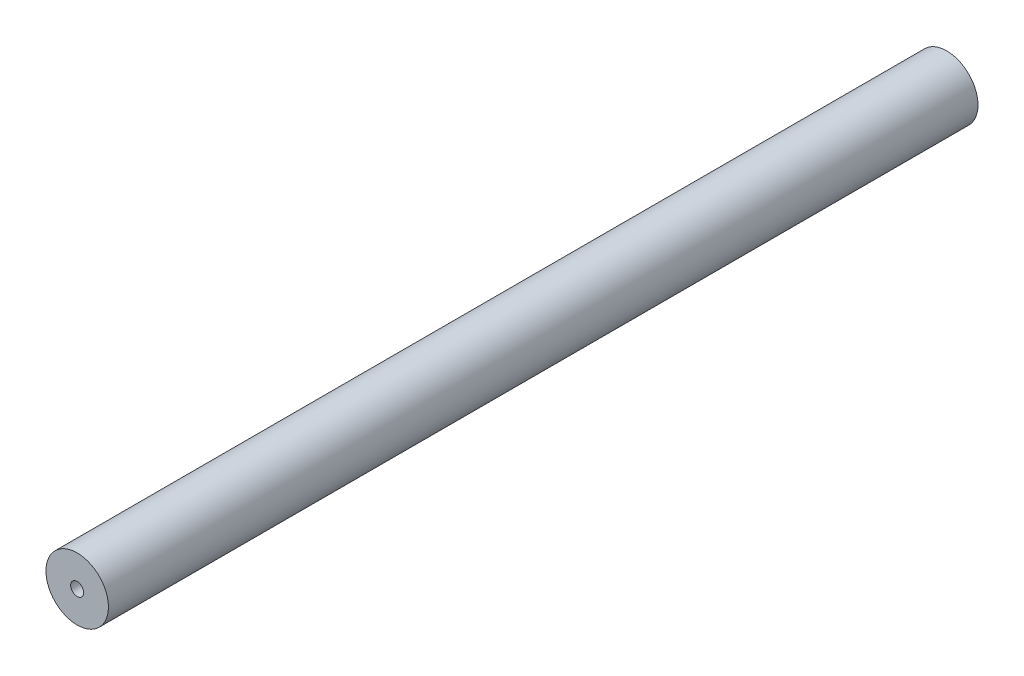
from build123d import *

# Parameters (mm, degrees)
SKETCH2_R           = 6
BOSS_EXTRUDE1_DEPTH = 83.5


with BuildPart() as part:
    # Sketch2 → Boss-Extrude1 (new body, symmetric)
    with BuildSketch(Plane.XY):
        Circle(SKETCH2_R)
    extrude(amount=BOSS_EXTRUDE1_DEPTH, both=True)

    # Sketch4 → Tap Drill for M3x0.5 Tap1 (revolve, cut)
    with BuildSketch(Plane(origin=(0, 0, 83.5), x_dir=(0, -1, 0), z_dir=(1, 0, 0))):
        Polygon((0, 0), (0, 10.751075774), (1.25, 10), (1.25, 0), align=None)
    tap_drill_for_m3x0_5_tap1 = revolve(axis=Axis((0, 0, 89.85), (0, 0, -1)), mode=Mode.SUBTRACT)

    # Mirror1: Tap Drill for M3x0.5 Tap1 across plane
    add(tap_drill_for_m3x0_5_tap1.mirror(Plane.XY), mode=Mode.SUBTRACT)


solid = part.part
